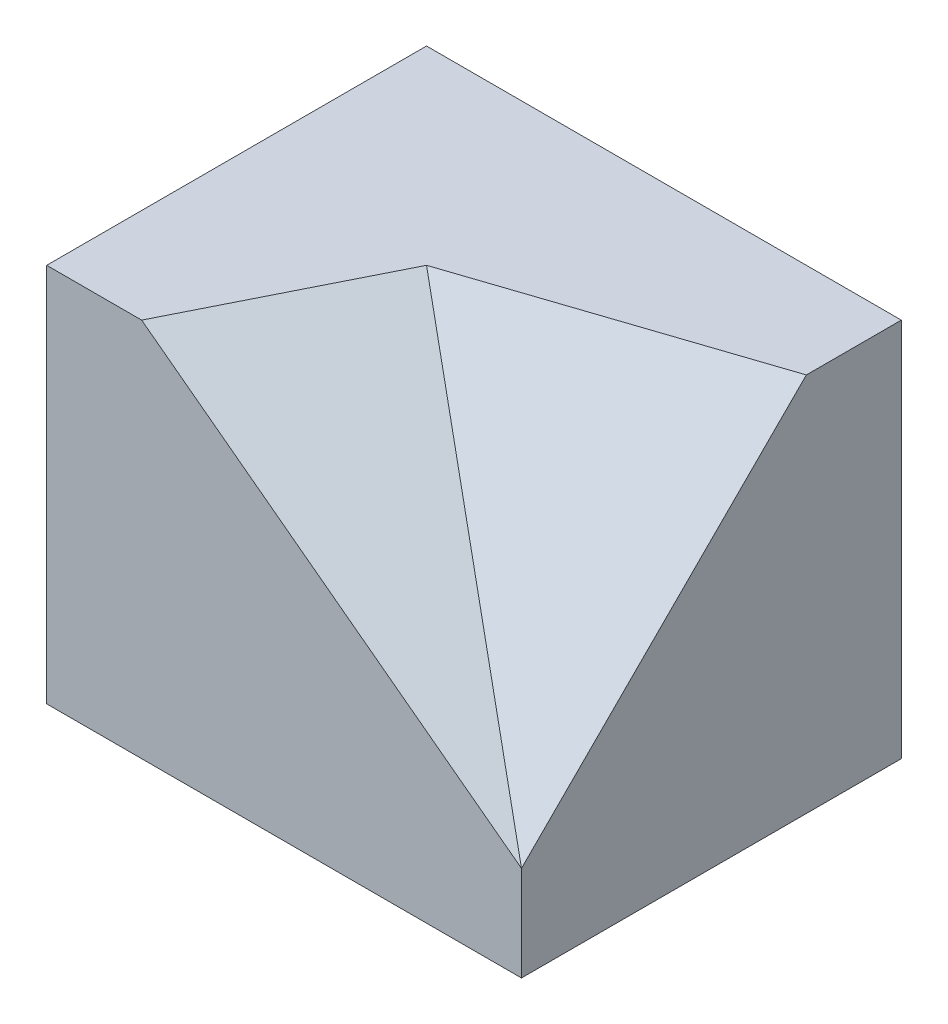
from build123d import *

# Parameters (mm, degrees)
SKETCH_1_W          = 25
SKETCH_1_H          = 20
EXTRUDE_1_DEPTH     = 20
CUT_EXTRUDE_1_DEPTH = 20
CUT_EXTRUDE_5_DEPTH = 20


with BuildPart() as part:
    # 草圖1 → 填料-伸長1 (new body)
    with BuildSketch(Plane(origin=(0, 0, 0), x_dir=(1, 0, 0), z_dir=(0, 1, 0))):
        Rectangle(SKETCH_1_W, SKETCH_1_H)
    extrude(amount=EXTRUDE_1_DEPTH)

    # 草圖5 → 除料-伸長1 (cut)
    with BuildSketch(Plane(origin=(7.981651376, 10.642201835, 3.990825688), x_dir=(-0.818367137, 0.538104419, 0.201789157), z_dir=(-0.574695771, -0.766261028, -0.287347886))):
        Polygon((-5.521175546, -7.607674568), (18.917733471, -2.340822944), (12.808006217, 7.022468832), align=None)
    extrude(amount=-CUT_EXTRUDE_1_DEPTH, mode=Mode.SUBTRACT)

    # 草圖7 → 除料-伸長5 (cut)
    with BuildSketch(Plane(origin=(3.026315789, 9.078947368, 9.078947368), x_dir=(0.973328527, -0.162221421, -0.162221421), z_dir=(0.229415734, 0.688247202, 0.688247202))):
        Polygon((9.733285268, -3.535533906), (9.733285268, 17.67766953), (-5.67774974, 14.142135624), align=None)
    extrude(amount=CUT_EXTRUDE_5_DEPTH, mode=Mode.SUBTRACT)


solid = part.part
